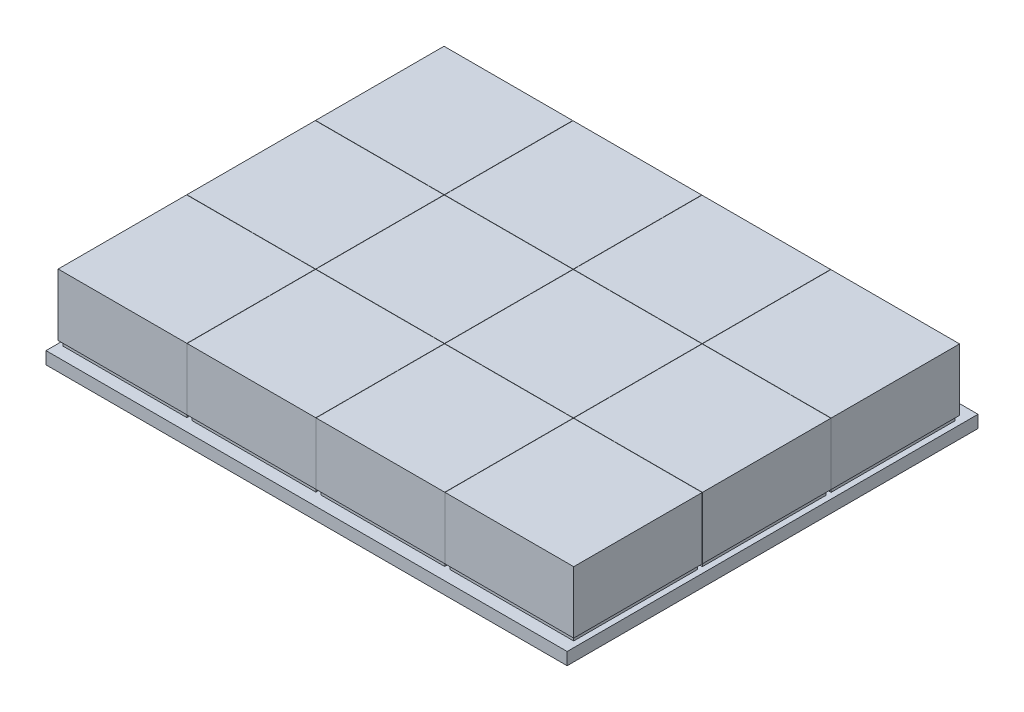
from build123d import *

# Parameters (mm, degrees)
SKETCH1_W                  = 500
SKETCH1_H                  = 166
BOSS_EXTRUDE1_DEPTH        = 5
SKETCH2_W                  = 50
SKETCH2_H                  = 50
BOSS_EXTRUDE3_DEPTH        = 2
LPATTERN1_COUNT            = 3
LPATTERN1_PITCH            = 52
SKETCH3_W                  = 52
SKETCH3_H                  = 51.9
BOSS_EXTRUDE8_DEPTH        = 25
LPATTERN5_COUNT            = 3
LPATTERN5_PITCH            = 52
LPATTERN6_COUNT            = 4
LPATTERN6_PITCH            = 52.1
LPATTERN6_COPY_1_SKETCH_W  = 50
LPATTERN6_COPY_1_SKETCH_H  = 50
LPATTERN6_COPY_1_DEPTH     = 2
LPATTERN6_COPY_2_SKETCH_W  = 50
LPATTERN6_COPY_2_SKETCH_H  = 50
LPATTERN6_COPY_2_DEPTH     = 2
LPATTERN6_COPY_3_SKETCH_W  = 50
LPATTERN6_COPY_3_SKETCH_H  = 50
LPATTERN6_COPY_3_DEPTH     = 2
LPATTERN6_COPY_4_SKETCH_W  = 50
LPATTERN6_COPY_4_SKETCH_H  = 50
LPATTERN6_COPY_4_DEPTH     = 2
LPATTERN6_COPY_5_SKETCH_W  = 50
LPATTERN6_COPY_5_SKETCH_H  = 50
LPATTERN6_COPY_5_DEPTH     = 2
LPATTERN6_COPY_6_SKETCH_W  = 50
LPATTERN6_COPY_6_SKETCH_H  = 50
LPATTERN6_COPY_6_DEPTH     = 2
LPATTERN6_COPY_7_SKETCH_W  = 52
LPATTERN6_COPY_7_SKETCH_H  = 51.9
LPATTERN6_COPY_7_DEPTH     = 25
LPATTERN6_COPY_8_SKETCH_W  = 52
LPATTERN6_COPY_8_SKETCH_H  = 51.9
LPATTERN6_COPY_8_DEPTH     = 25
LPATTERN6_COPY_9_SKETCH_W  = 52
LPATTERN6_COPY_9_SKETCH_H  = 51.9
LPATTERN6_COPY_9_DEPTH     = 25
LPATTERN6_COPY_10_SKETCH_W = 52
LPATTERN6_COPY_10_SKETCH_H = 51.9
LPATTERN6_COPY_10_DEPTH    = 25
LPATTERN6_COPY_11_SKETCH_W = 52
LPATTERN6_COPY_11_SKETCH_H = 51.9
LPATTERN6_COPY_11_DEPTH    = 25
LPATTERN6_COPY_12_SKETCH_W = 52
LPATTERN6_COPY_12_SKETCH_H = 51.9
LPATTERN6_COPY_12_DEPTH    = 25
SKETCH4_W                  = 223.089941366
SKETCH4_H                  = 166
SKETCH4_W_2                = 66.355147464
CUT_EXTRUDE1_DEPTH         = 10


with BuildPart() as part:
    # Sketch1 → Boss-Extrude1 (new body)
    with BuildSketch(Plane(origin=(0, 0, 0), x_dir=(1, 0, 0), z_dir=(0, 1, 0))):
        Rectangle(SKETCH1_W, SKETCH1_H)
    extrude(amount=BOSS_EXTRUDE1_DEPTH)

    # Sketch2 → Boss-Extrude3 (add)
    with BuildSketch(Plane(origin=(0, 5, 0), x_dir=(1, 0, 0), z_dir=(0, 1, 0))):
        with Locations((0, -53)):
            Rectangle(SKETCH2_W, SKETCH2_H)
    boss_extrude3 = extrude(amount=BOSS_EXTRUDE3_DEPTH)

    # LPattern1: Boss-Extrude3 ×3
    with Locations(*[(0, 0, -i * LPATTERN1_PITCH) for i in range(1, LPATTERN1_COUNT)]):
        add(boss_extrude3)

    # Sketch3 → Boss-Extrude8 (add)
    with BuildSketch(Plane(origin=(0, 7, 0), x_dir=(1, 0, 0), z_dir=(0, 1, 0))):
        with Locations((0, -53.05)):
            Rectangle(SKETCH3_W, SKETCH3_H)
    boss_extrude8 = extrude(amount=BOSS_EXTRUDE8_DEPTH)

    # LPattern5: Boss-Extrude8 ×3
    with Locations(*[(0, 0, -i * LPATTERN5_PITCH) for i in range(1, LPATTERN5_COUNT)]):
        add(boss_extrude8)

    # LPattern6: Boss-Extrude3, Boss-Extrude8 ×4
    with Locations(*[(i * LPATTERN6_PITCH, 0, 0) for i in range(1, LPATTERN6_COUNT)]):
        add(boss_extrude3)
        add(boss_extrude8)

    # LPattern6 copy 1 sketch → LPattern6 copy 1 (add)
    with BuildSketch(Plane(origin=(52.1, 5, -52), x_dir=(1, 0, 0), z_dir=(0, 1, 0))):
        with Locations((0, -53)):
            Rectangle(LPATTERN6_COPY_1_SKETCH_W, LPATTERN6_COPY_1_SKETCH_H)
    extrude(amount=LPATTERN6_COPY_1_DEPTH)

    # LPattern6 copy 2 sketch → LPattern6 copy 2 (add)
    with BuildSketch(Plane(origin=(104.2, 5, -52), x_dir=(1, 0, 0), z_dir=(0, 1, 0))):
        with Locations((0, -53)):
            Rectangle(LPATTERN6_COPY_2_SKETCH_W, LPATTERN6_COPY_2_SKETCH_H)
    extrude(amount=LPATTERN6_COPY_2_DEPTH)

    # LPattern6 copy 3 sketch → LPattern6 copy 3 (add)
    with BuildSketch(Plane(origin=(156.3, 5, -52), x_dir=(1, 0, 0), z_dir=(0, 1, 0))):
        with Locations((0, -53)):
            Rectangle(LPATTERN6_COPY_3_SKETCH_W, LPATTERN6_COPY_3_SKETCH_H)
    extrude(amount=LPATTERN6_COPY_3_DEPTH)

    # LPattern6 copy 4 sketch → LPattern6 copy 4 (add)
    with BuildSketch(Plane(origin=(52.1, 5, -104), x_dir=(1, 0, 0), z_dir=(0, 1, 0))):
        with Locations((0, -53)):
            Rectangle(LPATTERN6_COPY_4_SKETCH_W, LPATTERN6_COPY_4_SKETCH_H)
    extrude(amount=LPATTERN6_COPY_4_DEPTH)

    # LPattern6 copy 5 sketch → LPattern6 copy 5 (add)
    with BuildSketch(Plane(origin=(104.2, 5, -104), x_dir=(1, 0, 0), z_dir=(0, 1, 0))):
        with Locations((0, -53)):
            Rectangle(LPATTERN6_COPY_5_SKETCH_W, LPATTERN6_COPY_5_SKETCH_H)
    extrude(amount=LPATTERN6_COPY_5_DEPTH)

    # LPattern6 copy 6 sketch → LPattern6 copy 6 (add)
    with BuildSketch(Plane(origin=(156.3, 5, -104), x_dir=(1, 0, 0), z_dir=(0, 1, 0))):
        with Locations((0, -53)):
            Rectangle(LPATTERN6_COPY_6_SKETCH_W, LPATTERN6_COPY_6_SKETCH_H)
    extrude(amount=LPATTERN6_COPY_6_DEPTH)

    # LPattern6 copy 7 sketch → LPattern6 copy 7 (add)
    with BuildSketch(Plane(origin=(52.1, 7, -52), x_dir=(1, 0, 0), z_dir=(0, 1, 0))):
        with Locations((0, -53.05)):
            Rectangle(LPATTERN6_COPY_7_SKETCH_W, LPATTERN6_COPY_7_SKETCH_H)
    extrude(amount=LPATTERN6_COPY_7_DEPTH)

    # LPattern6 copy 8 sketch → LPattern6 copy 8 (add)
    with BuildSketch(Plane(origin=(104.2, 7, -52), x_dir=(1, 0, 0), z_dir=(0, 1, 0))):
        with Locations((0, -53.05)):
            Rectangle(LPATTERN6_COPY_8_SKETCH_W, LPATTERN6_COPY_8_SKETCH_H)
    extrude(amount=LPATTERN6_COPY_8_DEPTH)

    # LPattern6 copy 9 sketch → LPattern6 copy 9 (add)
    with BuildSketch(Plane(origin=(156.3, 7, -52), x_dir=(1, 0, 0), z_dir=(0, 1, 0))):
        with Locations((0, -53.05)):
            Rectangle(LPATTERN6_COPY_9_SKETCH_W, LPATTERN6_COPY_9_SKETCH_H)
    extrude(amount=LPATTERN6_COPY_9_DEPTH)

    # LPattern6 copy 10 sketch → LPattern6 copy 10 (add)
    with BuildSketch(Plane(origin=(52.1, 7, -104), x_dir=(1, 0, 0), z_dir=(0, 1, 0))):
        with Locations((0, -53.05)):
            Rectangle(LPATTERN6_COPY_10_SKETCH_W, LPATTERN6_COPY_10_SKETCH_H)
    extrude(amount=LPATTERN6_COPY_10_DEPTH)

    # LPattern6 copy 11 sketch → LPattern6 copy 11 (add)
    with BuildSketch(Plane(origin=(104.2, 7, -104), x_dir=(1, 0, 0), z_dir=(0, 1, 0))):
        with Locations((0, -53.05)):
            Rectangle(LPATTERN6_COPY_11_SKETCH_W, LPATTERN6_COPY_11_SKETCH_H)
    extrude(amount=LPATTERN6_COPY_11_DEPTH)

    # LPattern6 copy 12 sketch → LPattern6 copy 12 (add)
    with BuildSketch(Plane(origin=(156.3, 7, -104), x_dir=(1, 0, 0), z_dir=(0, 1, 0))):
        with Locations((0, -53.05)):
            Rectangle(LPATTERN6_COPY_12_SKETCH_W, LPATTERN6_COPY_12_SKETCH_H)
    extrude(amount=LPATTERN6_COPY_12_DEPTH)

    # Sketch4 → Cut-Extrude1 (cut)
    with BuildSketch(Plane(origin=(0, 5, 0), x_dir=(1, 0, 0), z_dir=(0, 1, 0))):
        with Locations((-138.455029317, 0)):
            Rectangle(SKETCH4_W, SKETCH4_H)
        with Locations((216.822426268, 0)):
            Rectangle(SKETCH4_W_2, SKETCH4_H)
    extrude(amount=-CUT_EXTRUDE1_DEPTH, mode=Mode.SUBTRACT)


solid = part.part
